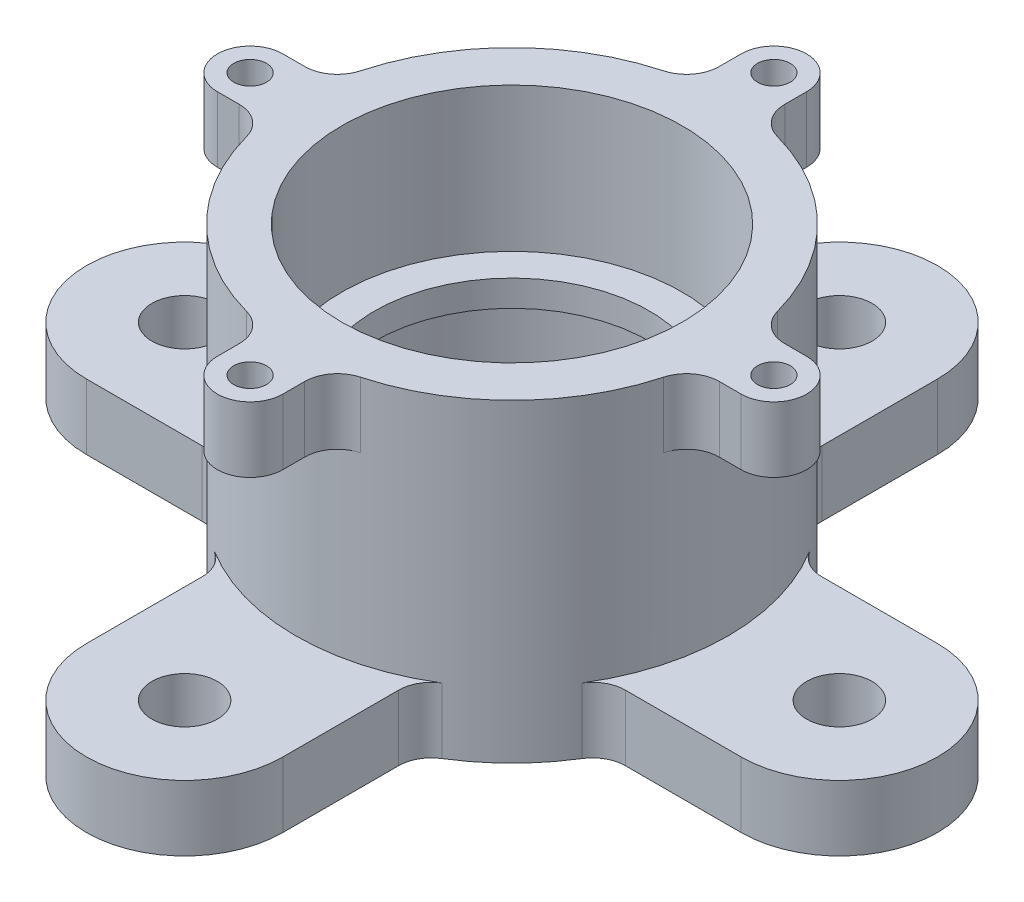
from build123d import *

# Parameters (mm, degrees)
SKETCH2_R           = 2.5
BOSS_EXTRUDE1_DEPTH = 10
SKETCH3_R           = 5
BOSS_EXTRUDE2_DEPTH = 10
FILLET1_R           = 5


with BuildPart() as part:
    # Sketch1 → Revolve1 (revolve)
    with BuildSketch(Plane.XY, mode=Mode.PRIVATE) as revolve1_sk:
        Polygon((26, 24), (26, 2), (21, 2), (21, -2), (26, -2), (26, -24), (33, -24), (33, 24), align=None)
    revolve(revolve1_sk.sketch.rotate(Axis((0, 27.182366668, 0), (0, -1, 0)), 90), axis=Axis((0, 27.182366668, 0), (0, -1, 0)))  # turned: the seam where the file's is

    # Sketch2 → Boss-Extrude1 (add)
    with BuildSketch(Plane.XZ.offset(-24)):
        with BuildLine():
            Line((5, 40), (5, 32.619012861))
            ThreePointArc((5, 32.619012861), (0, 33), (-5, 32.619012861))
            Line((-5, 32.619012861), (-5, 40))
            ThreePointArc((-5, 40), (0, 45), (5, 40))
        make_face()
        with Locations(Location((0, 40, 0), (0, 0, 270))):  # turned: the seam where the file's is
            Circle(SKETCH2_R, mode=Mode.SUBTRACT)
        with BuildLine():
            Line((40, -5), (32.619012861, -5))
            ThreePointArc((32.619012861, -5), (33, 0), (32.619012861, 5))
            Line((32.619012861, 5), (40, 5))
            ThreePointArc((40, 5), (45, 0), (40, -5))
        make_face()
        with Locations(Location((40, 0, 0), (0, 0, 270))):  # turned: the seam where the file's is
            Circle(SKETCH2_R, mode=Mode.SUBTRACT)
        with BuildLine():
            Line((-5, -40), (-5, -32.619012861))
            ThreePointArc((-5, -32.619012861), (0, -33), (5, -32.619012861))
            Line((5, -32.619012861), (5, -40))
            ThreePointArc((5, -40), (0, -45), (-5, -40))
        make_face()
        with Locations(Location((0, -40, 0), (0, 0, 270))):  # turned: the seam where the file's is
            Circle(SKETCH2_R, mode=Mode.SUBTRACT)
        with BuildLine():
            Line((-40, 5), (-32.619012861, 5))
            ThreePointArc((-32.619012861, 5), (-33, 0), (-32.619012861, -5))
            Line((-32.619012861, -5), (-40, -5))
            ThreePointArc((-40, -5), (-45, 0), (-40, 5))
        make_face()
        with Locations(Location((-40, 0, 0), (0, 0, 270))):  # turned: the seam where the file's is
            Circle(SKETCH2_R, mode=Mode.SUBTRACT)
    extrude(amount=BOSS_EXTRUDE1_DEPTH)

    # Sketch3 → Boss-Extrude2 (add)
    with BuildSketch(Plane(origin=(0, -24, 0), x_dir=(-1, 0, 0), z_dir=(0, 1, 0))):
        with BuildLine():
            Line((-15, 50), (-15, 29.393876913))
            ThreePointArc((-15, 29.393876913), (0, 33), (15, 29.393876913))
            Line((15, 29.393876913), (15, 50))
            ThreePointArc((15, 50), (0, 65), (-15, 50))
        make_face()
        with Locations(Location((0, 50, 0), (0, 0, 90))):  # turned: the seam where the file's is
            Circle(SKETCH3_R, mode=Mode.SUBTRACT)
        with BuildLine():
            Line((50, 15), (29.393876913, 15))
            ThreePointArc((29.393876913, 15), (33, 0), (29.393876913, -15))
            Line((29.393876913, -15), (50, -15))
            ThreePointArc((50, -15), (65, 0), (50, 15))
        make_face()
        with Locations(Location((50, 0, 0), (0, 0, 90))):  # turned: the seam where the file's is
            Circle(SKETCH3_R, mode=Mode.SUBTRACT)
        with BuildLine():
            Line((15, -50), (15, -29.393876913))
            ThreePointArc((15, -29.393876913), (0, -33), (-15, -29.393876913))
            Line((-15, -29.393876913), (-15, -50))
            ThreePointArc((-15, -50), (0, -65), (15, -50))
        make_face()
        with Locations(Location((0, -50, 0), (0, 0, 90))):  # turned: the seam where the file's is
            Circle(SKETCH3_R, mode=Mode.SUBTRACT)
        with BuildLine():
            Line((-50, -15), (-29.393876913, -15))
            ThreePointArc((-29.393876913, -15), (-33, 0), (-29.393876913, 15))
            Line((-29.393876913, 15), (-50, 15))
            ThreePointArc((-50, 15), (-65, 0), (-50, -15))
        make_face()
        with Locations(Location((-50, 0, 0), (0, 0, 90))):  # turned: the seam where the file's is
            Circle(SKETCH3_R, mode=Mode.SUBTRACT)
    extrude(amount=BOSS_EXTRUDE2_DEPTH)

    # Fillet1
    fillet1_edges = [part.edges().sort_by_distance(p)[0] for p in [
        (-15, -19, -29.393876913),
        (15, -19, -29.393876913),
        (29.393876913, -19, -15),
        (29.393876913, -19, 15),
        (-5, 19, 32.619012861),
        (5, 19, 32.619012861),
        (32.619012861, 19, 5),
        (32.619012861, 19, -5),
        (5, 19, -32.619012861),
        (-5, 19, -32.619012861),
        (-32.619012861, 19, -5),
        (-32.619012861, 19, 5),
        (15, -19, 29.393876913),
        (-15, -19, 29.393876913),
        (-29.393876913, -19, 15),
        (-29.393876913, -19, -15),
    ]]
    fillet(fillet1_edges, radius=FILLET1_R)


solid = part.part
